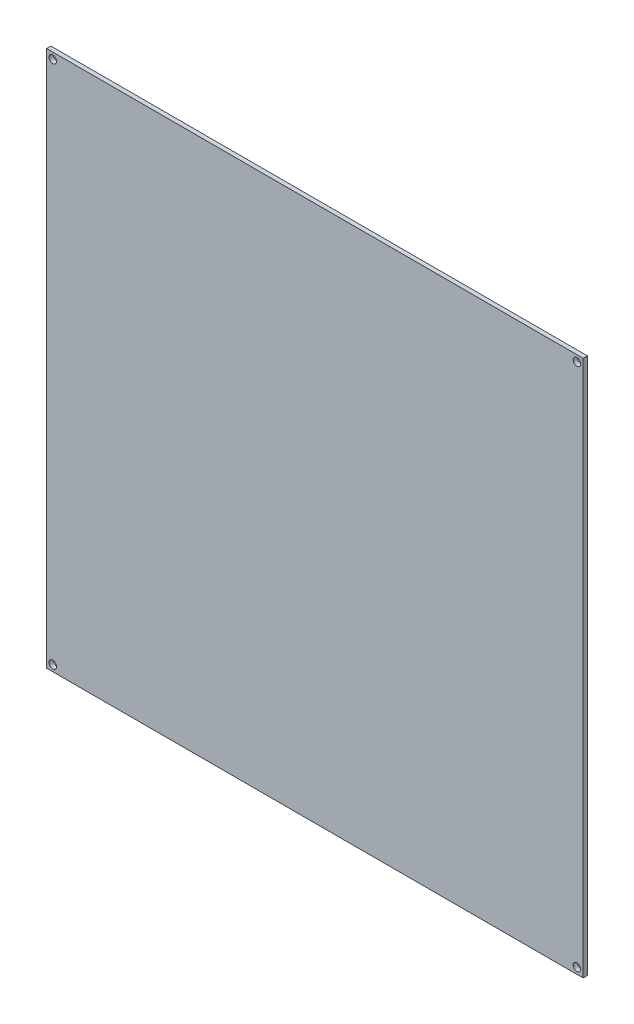
from build123d import *

# Parameters (mm, degrees)
SCHIZZO2_W                   = 214
SCHIZZO2_H                   = 214
SCHIZZO2_R                   = 1.5
ESTRUSIONE_ESTRUSIONE2_DEPTH = 1.7


with BuildPart() as part:
    # Schizzo2 → Estrusione-Estrusione2 (new body)
    with BuildSketch(Plane.XY):
        with Locations((107, 107)):
            Rectangle(SCHIZZO2_W, SCHIZZO2_H)
        with Locations((2.5, 211.5)):
            Circle(SCHIZZO2_R, mode=Mode.SUBTRACT)
        with Locations((211.5, 211.5)):
            Circle(SCHIZZO2_R, mode=Mode.SUBTRACT)
        with Locations((211.5, 2.5)):
            Circle(SCHIZZO2_R, mode=Mode.SUBTRACT)
        with Locations((2.5, 2.5)):
            Circle(SCHIZZO2_R, mode=Mode.SUBTRACT)
    extrude(amount=-ESTRUSIONE_ESTRUSIONE2_DEPTH)


solid = part.part
